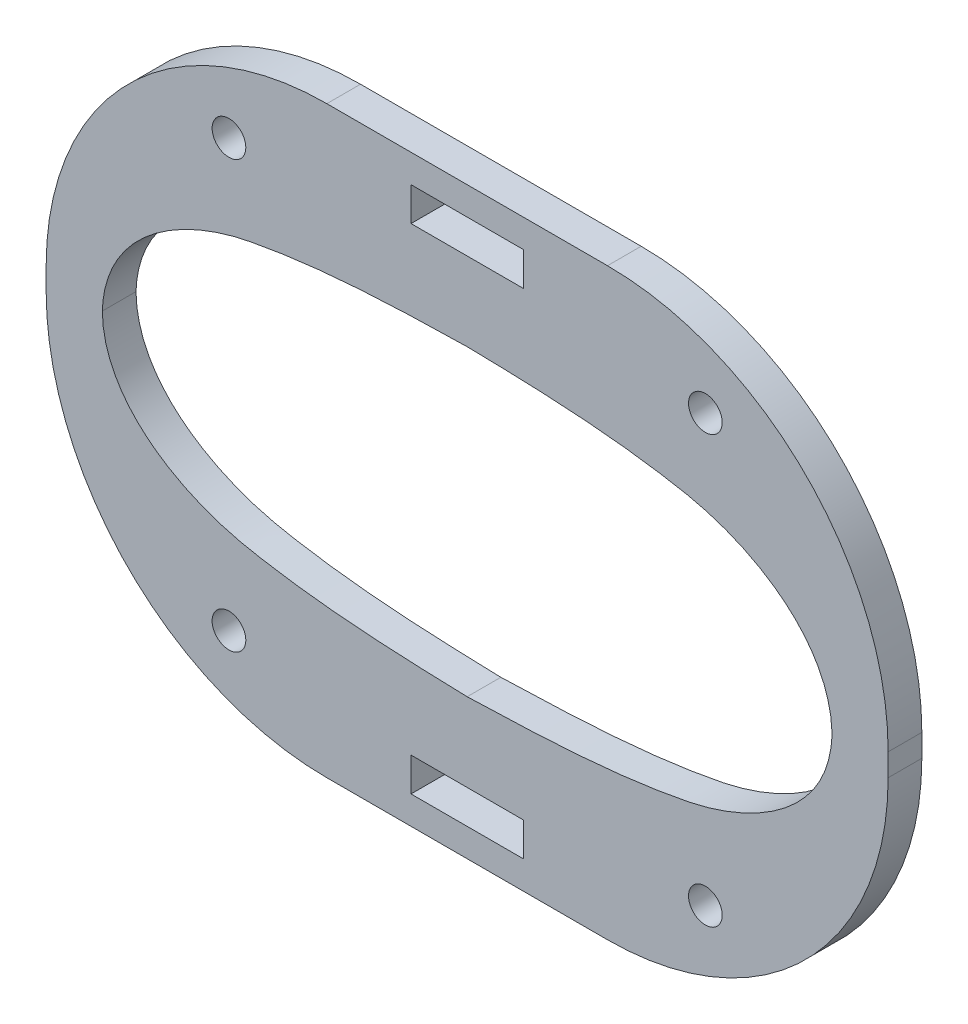
from build123d import *

# Parameters (mm, degrees)
ESBO_O1_R                = 1.5
ESBO_O1_W                = 10
ESBO_O1_H                = 3
RESSALTO_EXTRUS_O1_DEPTH = 3


with BuildPart() as part:
    # Esboço1 → Ressalto-extrusão1 (new body)
    with BuildSketch(Plane.XY):
        with BuildLine():
            Line((12.5, 26), (-12.5, 26))
            ThreePointArc((-12.5, 26), (-30.17766953, 18.67766953), (-37.5, 1))
            Line((-37.5, 1), (-37.5, -1))
            ThreePointArc((-37.5, -1), (-30.17766953, -18.67766953), (-12.5, -26))
            Line((-12.5, -26), (12.5, -26))
            ThreePointArc((12.5, -26), (30.17766953, -18.67766953), (37.5, -1))
            Line((37.5, -1), (37.5, 1))
            ThreePointArc((37.5, 1), (30.17766953, 18.67766953), (12.5, 26))
        make_face()
        with Locations((21.217797887, -19)):
            Circle(ESBO_O1_R, mode=Mode.SUBTRACT)
        with Locations((-21.217797887, -19)):
            Circle(ESBO_O1_R, mode=Mode.SUBTRACT)
        with Locations((21.217797887, 19)):
            Circle(ESBO_O1_R, mode=Mode.SUBTRACT)
        with Locations((-21.217797887, 19)):
            Circle(ESBO_O1_R, mode=Mode.SUBTRACT)
        with Locations((0, -22)):
            Rectangle(ESBO_O1_W, ESBO_O1_H, mode=Mode.SUBTRACT)
        with Locations((0, 22)):
            Rectangle(ESBO_O1_W, ESBO_O1_H, mode=Mode.SUBTRACT)
        with BuildLine():
            add(Edge.make_bspline(
                [(0, 13.5), (-6.514313954, 13.371702924), (-13.061550247, 13.159493855), (-25.841412433, 10.670468151), (-32.278969705, 6.557006437), (-32.5, 0)],
                knots=[0, 0, 0, 0, 0.5, 0.5, 1, 1, 1, 1], degree=3))
            add(Edge.make_bspline(
                [(-32.5, 0), (-32.427257733, -6.547836692), (-25.851452541, -10.56016062), (-13.054919404, -13.052475621), (-6.515644351, -13.308712796), (0, -13.5)],
                knots=[0, 0, 0, 0, 0.5, 0.5, 1, 1, 1, 1], degree=3))
            add(Edge.make_bspline(
                [(32.5, 0), (32.427257733, -6.547836692), (25.851452541, -10.56016062), (13.054919404, -13.052475621), (6.515644351, -13.308712796), (0, -13.5)],
                knots=[0, 0, 0, 0, 0.5, 0.5, 1, 1, 1, 1], degree=3))
            add(Edge.make_bspline(
                [(0, 13.5), (6.514313954, 13.371702924), (13.061550247, 13.159493855), (25.841412433, 10.670468151), (32.278969705, 6.557006437), (32.5, 0)],
                knots=[0, 0, 0, 0, 0.5, 0.5, 1, 1, 1, 1], degree=3))
        make_face(mode=Mode.SUBTRACT)
    extrude(amount=RESSALTO_EXTRUS_O1_DEPTH)


solid = part.part
